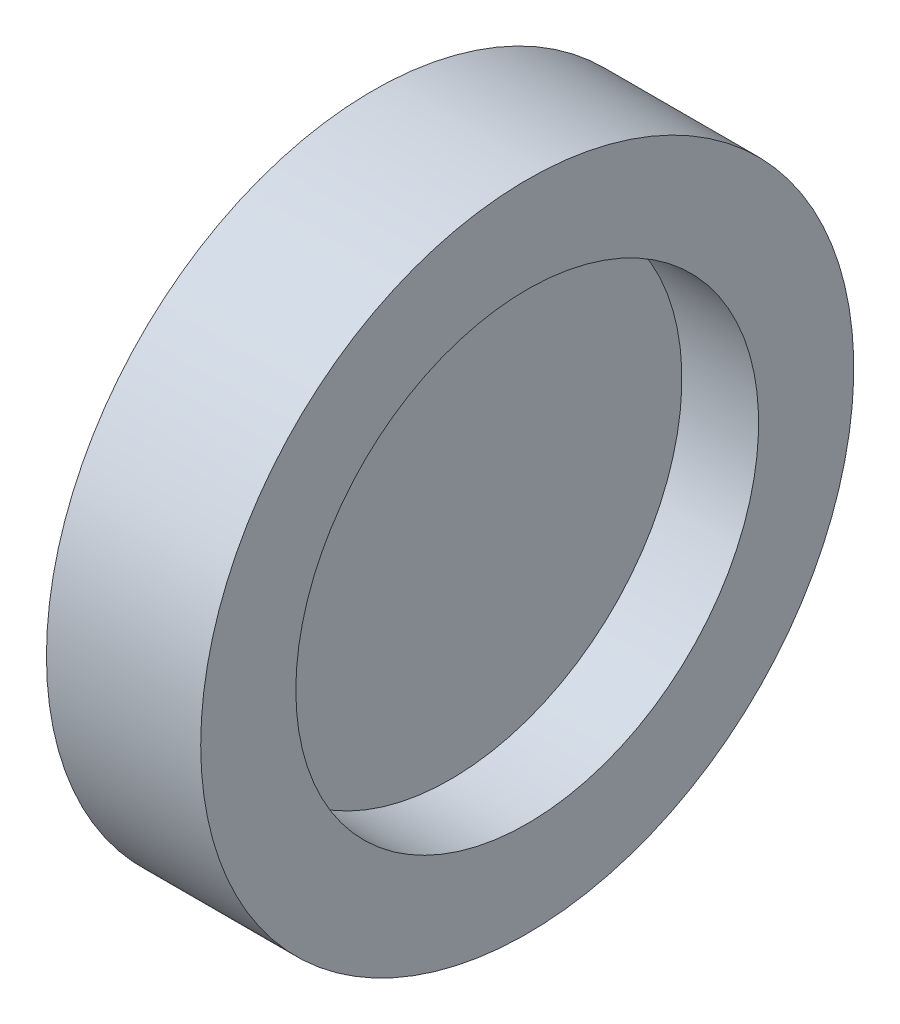
from build123d import *

# Parameters (mm, degrees)
SKETCH_1_W = 0.029
SKETCH_1_H = 9
SKETCH_4_W = 6
SKETCH_4_H = 3.7


with BuildPart() as part:
    # 草图1 → 旋转2 (revolve)
    with BuildSketch(Plane.XY, mode=Mode.PRIVATE) as revolve_2_sk:
        with Locations((0, 4.5)):
            Rectangle(SKETCH_1_W, SKETCH_1_H)
    revolve(revolve_2_sk.sketch.rotate(Axis((-0.0145, 0, 0), (1, 0, 0)), 90), axis=Axis((-0.0145, 0, 0), (1, 0, 0)))  # turned: the seam where the file's is

    # 草图4 → 旋转3 (revolve)
    with BuildSketch(Plane.XY, mode=Mode.PRIVATE) as revolve_3_sk:
        with Locations((0, 10.85)):
            Rectangle(SKETCH_4_W, SKETCH_4_H)
    revolve(revolve_3_sk.sketch.rotate(Axis((-1.614212419, 0, 0), (1, 0, 0)), 90), axis=Axis((-1.614212419, 0, 0), (1, 0, 0)))  # turned: the seam where the file's is


solid = part.part
